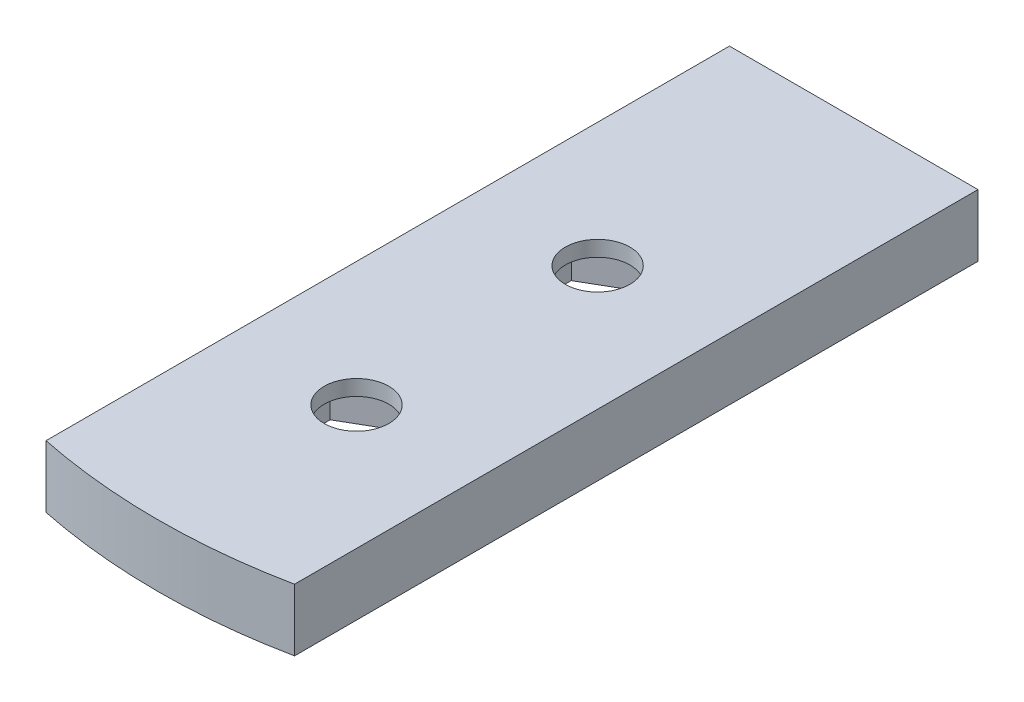
from build123d import *

# Parameters (mm, degrees)
BOSS_EXTRUDE1_DEPTH = 2.38125
SKETCH2_R           = 1.651
BOSS_EXTRUDE2_DEPTH = 0.79375


with BuildPart() as part:
    # Sketch1 → Boss-Extrude1 (new body)
    with BuildSketch(Plane(origin=(0, 0, 0), x_dir=(1, 0, 0), z_dir=(0, 1, 0))):
        with BuildLine():
            Line((-6.355837102, -10.127283918), (6.344162898, -10.127283918))
            Line((6.344162898, -10.127283918), (6.344162898, -45.052283918))
            ThreePointArc((6.344162898, -45.052283918), (-0.005837102, -45.693764185), (-6.355837102, -45.052283918))
            Line((-6.355837102, -45.052283918), (-6.355837102, -10.127283918))
        make_face()
        Polygon((3.181862898, -25.055183638), (3.181862898, -21.374344732), (-0.005837102, -19.533925278), (-3.193537102, -21.374344732), (-3.193537102, -25.055183638), (-0.005837102, -26.895603091), align=None, mode=Mode.SUBTRACT)
        Polygon((3.181862898, -37.374183638), (3.181862898, -33.693344732), (-0.005837102, -31.852925278), (-3.193537102, -33.693344732), (-3.193537102, -37.374183638), (-0.005837102, -39.214603091), align=None, mode=Mode.SUBTRACT)
    extrude(amount=BOSS_EXTRUDE1_DEPTH)

    # Sketch2 → Boss-Extrude2 (add)
    with BuildSketch(Plane(origin=(0, 2.38125, 0), x_dir=(1, 0, 0), z_dir=(0, 1, 0))):
        with BuildLine():
            Line((6.344162898, -45.052283918), (6.344162898, -10.127283918))
            Line((6.344162898, -10.127283918), (-6.355837102, -10.127283918))
            Line((-6.355837102, -10.127283918), (-6.355837102, -45.052283918))
            ThreePointArc((-6.355837102, -45.052283918), (-0.005837102, -45.693764185), (6.344162898, -45.052283918))
        make_face()
        with Locations((-0.005837102, -23.214764185)):
            Circle(SKETCH2_R, mode=Mode.SUBTRACT)
        with Locations((-0.005837102, -35.533764185)):
            Circle(SKETCH2_R, mode=Mode.SUBTRACT)
    extrude(amount=BOSS_EXTRUDE2_DEPTH)


solid = part.part
